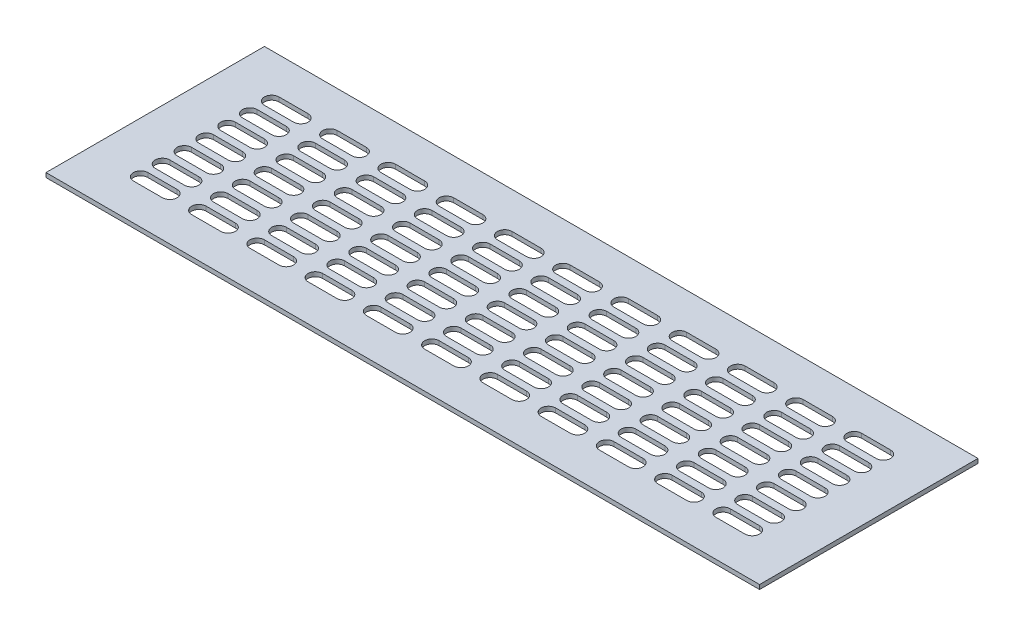
from build123d import *

# Parameters (mm, degrees)
SKETCH1_W           = 490
SKETCH1_H           = 150
BOSS_EXTRUDE1_DEPTH = 1.5
CUT_EXTRUDE1_DEPTH  = 4


with BuildPart() as part:
    # Sketch1 → Boss-Extrude1 (new body, symmetric)
    with BuildSketch(Plane(origin=(0, 0, 0), x_dir=(1, 0, 0), z_dir=(0, 1, 0))):
        Rectangle(SKETCH1_W, SKETCH1_H)
    extrude(amount=BOSS_EXTRUDE1_DEPTH, both=True)

    # Sketch2 → Cut-Extrude1 (cut, through all)
    with BuildSketch(Plane(origin=(0, 1.5, 0), x_dir=(1, 0, 0), z_dir=(0, 1, 0))):
        with BuildLine():
            Line((-210, 50), (-190, 50))
            ThreePointArc((-190, 50), (-185, 45), (-190, 40))
            Line((-190, 40), (-210, 40))
            ThreePointArc((-210, 40), (-215, 45), (-210, 50))
        make_face()
        with BuildLine():
            Line((-170, 50), (-150, 50))
            ThreePointArc((-150, 50), (-145, 45), (-150, 40))
            Line((-150, 40), (-170, 40))
            ThreePointArc((-170, 40), (-175, 45), (-170, 50))
        make_face()
        with BuildLine():
            Line((-130, 50), (-110, 50))
            ThreePointArc((-110, 50), (-105, 45), (-110, 40))
            Line((-110, 40), (-130, 40))
            ThreePointArc((-130, 40), (-135, 45), (-130, 50))
        make_face()
        with BuildLine():
            Line((-90, 50), (-70, 50))
            ThreePointArc((-70, 50), (-65, 45), (-70, 40))
            Line((-70, 40), (-90, 40))
            ThreePointArc((-90, 40), (-95, 45), (-90, 50))
        make_face()
        with BuildLine():
            Line((-50, 50), (-30, 50))
            ThreePointArc((-30, 50), (-25, 45), (-30, 40))
            Line((-30, 40), (-50, 40))
            ThreePointArc((-50, 40), (-55, 45), (-50, 50))
        make_face()
        with BuildLine():
            Line((-10, 50), (10, 50))
            ThreePointArc((10, 50), (15, 45), (10, 40))
            Line((10, 40), (-10, 40))
            ThreePointArc((-10, 40), (-15, 45), (-10, 50))
        make_face()
        with BuildLine():
            Line((30, 50), (50, 50))
            ThreePointArc((50, 50), (55, 45), (50, 40))
            Line((50, 40), (30, 40))
            ThreePointArc((30, 40), (25, 45), (30, 50))
        make_face()
        with BuildLine():
            Line((70, 50), (90, 50))
            ThreePointArc((90, 50), (95, 45), (90, 40))
            Line((90, 40), (70, 40))
            ThreePointArc((70, 40), (65, 45), (70, 50))
        make_face()
        with BuildLine():
            Line((110, 50), (130, 50))
            ThreePointArc((130, 50), (135, 45), (130, 40))
            Line((130, 40), (110, 40))
            ThreePointArc((110, 40), (105, 45), (110, 50))
        make_face()
        with BuildLine():
            Line((150, 50), (170, 50))
            ThreePointArc((170, 50), (175, 45), (170, 40))
            Line((170, 40), (150, 40))
            ThreePointArc((150, 40), (145, 45), (150, 50))
        make_face()
        with BuildLine():
            Line((190, 50), (210, 50))
            ThreePointArc((210, 50), (215, 45), (210, 40))
            Line((210, 40), (190, 40))
            ThreePointArc((190, 40), (185, 45), (190, 50))
        make_face()
        with BuildLine():
            Line((-170, 35), (-150, 35))
            ThreePointArc((-150, 35), (-145, 30), (-150, 25))
            Line((-150, 25), (-170, 25))
            ThreePointArc((-170, 25), (-175, 30), (-170, 35))
        make_face()
        with BuildLine():
            Line((-130, 35), (-110, 35))
            ThreePointArc((-110, 35), (-105, 30), (-110, 25))
            Line((-110, 25), (-130, 25))
            ThreePointArc((-130, 25), (-135, 30), (-130, 35))
        make_face()
        with BuildLine():
            Line((-90, 35), (-70, 35))
            ThreePointArc((-70, 35), (-65, 30), (-70, 25))
            Line((-70, 25), (-90, 25))
            ThreePointArc((-90, 25), (-95, 30), (-90, 35))
        make_face()
        with BuildLine():
            Line((-50, 35), (-30, 35))
            ThreePointArc((-30, 35), (-25, 30), (-30, 25))
            Line((-30, 25), (-50, 25))
            ThreePointArc((-50, 25), (-55, 30), (-50, 35))
        make_face()
        with BuildLine():
            Line((-10, 35), (10, 35))
            ThreePointArc((10, 35), (15, 30), (10, 25))
            Line((10, 25), (-10, 25))
            ThreePointArc((-10, 25), (-15, 30), (-10, 35))
        make_face()
        with BuildLine():
            Line((30, 35), (50, 35))
            ThreePointArc((50, 35), (55, 30), (50, 25))
            Line((50, 25), (30, 25))
            ThreePointArc((30, 25), (25, 30), (30, 35))
        make_face()
        with BuildLine():
            Line((70, 35), (90, 35))
            ThreePointArc((90, 35), (95, 30), (90, 25))
            Line((90, 25), (70, 25))
            ThreePointArc((70, 25), (65, 30), (70, 35))
        make_face()
        with BuildLine():
            Line((110, 35), (130, 35))
            ThreePointArc((130, 35), (135, 30), (130, 25))
            Line((130, 25), (110, 25))
            ThreePointArc((110, 25), (105, 30), (110, 35))
        make_face()
        with BuildLine():
            Line((150, 35), (170, 35))
            ThreePointArc((170, 35), (175, 30), (170, 25))
            Line((170, 25), (150, 25))
            ThreePointArc((150, 25), (145, 30), (150, 35))
        make_face()
        with BuildLine():
            Line((190, 35), (210, 35))
            ThreePointArc((210, 35), (215, 30), (210, 25))
            Line((210, 25), (190, 25))
            ThreePointArc((190, 25), (185, 30), (190, 35))
        make_face()
        with BuildLine():
            Line((-170, 20), (-150, 20))
            ThreePointArc((-150, 20), (-145, 15), (-150, 10))
            Line((-150, 10), (-170, 10))
            ThreePointArc((-170, 10), (-175, 15), (-170, 20))
        make_face()
        with BuildLine():
            Line((-130, 20), (-110, 20))
            ThreePointArc((-110, 20), (-105, 15), (-110, 10))
            Line((-110, 10), (-130, 10))
            ThreePointArc((-130, 10), (-135, 15), (-130, 20))
        make_face()
        with BuildLine():
            Line((-90, 20), (-70, 20))
            ThreePointArc((-70, 20), (-65, 15), (-70, 10))
            Line((-70, 10), (-90, 10))
            ThreePointArc((-90, 10), (-95, 15), (-90, 20))
        make_face()
        with BuildLine():
            Line((-50, 20), (-30, 20))
            ThreePointArc((-30, 20), (-25, 15), (-30, 10))
            Line((-30, 10), (-50, 10))
            ThreePointArc((-50, 10), (-55, 15), (-50, 20))
        make_face()
        with BuildLine():
            Line((-10, 20), (10, 20))
            ThreePointArc((10, 20), (15, 15), (10, 10))
            Line((10, 10), (-10, 10))
            ThreePointArc((-10, 10), (-15, 15), (-10, 20))
        make_face()
        with BuildLine():
            Line((30, 20), (50, 20))
            ThreePointArc((50, 20), (55, 15), (50, 10))
            Line((50, 10), (30, 10))
            ThreePointArc((30, 10), (25, 15), (30, 20))
        make_face()
        with BuildLine():
            Line((70, 20), (90, 20))
            ThreePointArc((90, 20), (95, 15), (90, 10))
            Line((90, 10), (70, 10))
            ThreePointArc((70, 10), (65, 15), (70, 20))
        make_face()
        with BuildLine():
            Line((110, 20), (130, 20))
            ThreePointArc((130, 20), (135, 15), (130, 10))
            Line((130, 10), (110, 10))
            ThreePointArc((110, 10), (105, 15), (110, 20))
        make_face()
        with BuildLine():
            Line((150, 20), (170, 20))
            ThreePointArc((170, 20), (175, 15), (170, 10))
            Line((170, 10), (150, 10))
            ThreePointArc((150, 10), (145, 15), (150, 20))
        make_face()
        with BuildLine():
            Line((190, 20), (210, 20))
            ThreePointArc((210, 20), (215, 15), (210, 10))
            Line((210, 10), (190, 10))
            ThreePointArc((190, 10), (185, 15), (190, 20))
        make_face()
        with BuildLine():
            Line((-170, 5), (-150, 5))
            ThreePointArc((-150, 5), (-145, 0), (-150, -5))
            Line((-150, -5), (-170, -5))
            ThreePointArc((-170, -5), (-175, 0), (-170, 5))
        make_face()
        with BuildLine():
            Line((-130, 5), (-110, 5))
            ThreePointArc((-110, 5), (-105, 0), (-110, -5))
            Line((-110, -5), (-130, -5))
            ThreePointArc((-130, -5), (-135, 0), (-130, 5))
        make_face()
        with BuildLine():
            Line((-90, 5), (-70, 5))
            ThreePointArc((-70, 5), (-65, 0), (-70, -5))
            Line((-70, -5), (-90, -5))
            ThreePointArc((-90, -5), (-95, 0), (-90, 5))
        make_face()
        with BuildLine():
            Line((-50, 5), (-30, 5))
            ThreePointArc((-30, 5), (-25, 0), (-30, -5))
            Line((-30, -5), (-50, -5))
            ThreePointArc((-50, -5), (-55, 0), (-50, 5))
        make_face()
        with BuildLine():
            Line((-10, 5), (10, 5))
            ThreePointArc((10, 5), (15, 0), (10, -5))
            Line((10, -5), (-10, -5))
            ThreePointArc((-10, -5), (-15, 0), (-10, 5))
        make_face()
        with BuildLine():
            Line((30, 5), (50, 5))
            ThreePointArc((50, 5), (55, 0), (50, -5))
            Line((50, -5), (30, -5))
            ThreePointArc((30, -5), (25, 0), (30, 5))
        make_face()
        with BuildLine():
            Line((70, 5), (90, 5))
            ThreePointArc((90, 5), (95, 0), (90, -5))
            Line((90, -5), (70, -5))
            ThreePointArc((70, -5), (65, 0), (70, 5))
        make_face()
        with BuildLine():
            Line((110, 5), (130, 5))
            ThreePointArc((130, 5), (135, 0), (130, -5))
            Line((130, -5), (110, -5))
            ThreePointArc((110, -5), (105, 0), (110, 5))
        make_face()
        with BuildLine():
            Line((150, 5), (170, 5))
            ThreePointArc((170, 5), (175, 0), (170, -5))
            Line((170, -5), (150, -5))
            ThreePointArc((150, -5), (145, 0), (150, 5))
        make_face()
        with BuildLine():
            Line((190, 5), (210, 5))
            ThreePointArc((210, 5), (215, 0), (210, -5))
            Line((210, -5), (190, -5))
            ThreePointArc((190, -5), (185, 0), (190, 5))
        make_face()
        with BuildLine():
            Line((-170, -10), (-150, -10))
            ThreePointArc((-150, -10), (-145, -15), (-150, -20))
            Line((-150, -20), (-170, -20))
            ThreePointArc((-170, -20), (-175, -15), (-170, -10))
        make_face()
        with BuildLine():
            Line((-130, -10), (-110, -10))
            ThreePointArc((-110, -10), (-105, -15), (-110, -20))
            Line((-110, -20), (-130, -20))
            ThreePointArc((-130, -20), (-135, -15), (-130, -10))
        make_face()
        with BuildLine():
            Line((-90, -10), (-70, -10))
            ThreePointArc((-70, -10), (-65, -15), (-70, -20))
            Line((-70, -20), (-90, -20))
            ThreePointArc((-90, -20), (-95, -15), (-90, -10))
        make_face()
        with BuildLine():
            Line((-50, -10), (-30, -10))
            ThreePointArc((-30, -10), (-25, -15), (-30, -20))
            Line((-30, -20), (-50, -20))
            ThreePointArc((-50, -20), (-55, -15), (-50, -10))
        make_face()
        with BuildLine():
            Line((-10, -10), (10, -10))
            ThreePointArc((10, -10), (15, -15), (10, -20))
            Line((10, -20), (-10, -20))
            ThreePointArc((-10, -20), (-15, -15), (-10, -10))
        make_face()
        with BuildLine():
            Line((30, -10), (50, -10))
            ThreePointArc((50, -10), (55, -15), (50, -20))
            Line((50, -20), (30, -20))
            ThreePointArc((30, -20), (25, -15), (30, -10))
        make_face()
        with BuildLine():
            Line((70, -10), (90, -10))
            ThreePointArc((90, -10), (95, -15), (90, -20))
            Line((90, -20), (70, -20))
            ThreePointArc((70, -20), (65, -15), (70, -10))
        make_face()
        with BuildLine():
            Line((110, -10), (130, -10))
            ThreePointArc((130, -10), (135, -15), (130, -20))
            Line((130, -20), (110, -20))
            ThreePointArc((110, -20), (105, -15), (110, -10))
        make_face()
        with BuildLine():
            Line((150, -10), (170, -10))
            ThreePointArc((170, -10), (175, -15), (170, -20))
            Line((170, -20), (150, -20))
            ThreePointArc((150, -20), (145, -15), (150, -10))
        make_face()
        with BuildLine():
            Line((190, -10), (210, -10))
            ThreePointArc((210, -10), (215, -15), (210, -20))
            Line((210, -20), (190, -20))
            ThreePointArc((190, -20), (185, -15), (190, -10))
        make_face()
        with BuildLine():
            Line((-170, -25), (-150, -25))
            ThreePointArc((-150, -25), (-145, -30), (-150, -35))
            Line((-150, -35), (-170, -35))
            ThreePointArc((-170, -35), (-175, -30), (-170, -25))
        make_face()
        with BuildLine():
            Line((-130, -25), (-110, -25))
            ThreePointArc((-110, -25), (-105, -30), (-110, -35))
            Line((-110, -35), (-130, -35))
            ThreePointArc((-130, -35), (-135, -30), (-130, -25))
        make_face()
        with BuildLine():
            Line((-90, -25), (-70, -25))
            ThreePointArc((-70, -25), (-65, -30), (-70, -35))
            Line((-70, -35), (-90, -35))
            ThreePointArc((-90, -35), (-95, -30), (-90, -25))
        make_face()
        with BuildLine():
            Line((-50, -25), (-30, -25))
            ThreePointArc((-30, -25), (-25, -30), (-30, -35))
            Line((-30, -35), (-50, -35))
            ThreePointArc((-50, -35), (-55, -30), (-50, -25))
        make_face()
        with BuildLine():
            Line((-10, -25), (10, -25))
            ThreePointArc((10, -25), (15, -30), (10, -35))
            Line((10, -35), (-10, -35))
            ThreePointArc((-10, -35), (-15, -30), (-10, -25))
        make_face()
        with BuildLine():
            Line((30, -25), (50, -25))
            ThreePointArc((50, -25), (55, -30), (50, -35))
            Line((50, -35), (30, -35))
            ThreePointArc((30, -35), (25, -30), (30, -25))
        make_face()
        with BuildLine():
            Line((70, -25), (90, -25))
            ThreePointArc((90, -25), (95, -30), (90, -35))
            Line((90, -35), (70, -35))
            ThreePointArc((70, -35), (65, -30), (70, -25))
        make_face()
        with BuildLine():
            Line((110, -25), (130, -25))
            ThreePointArc((130, -25), (135, -30), (130, -35))
            Line((130, -35), (110, -35))
            ThreePointArc((110, -35), (105, -30), (110, -25))
        make_face()
        with BuildLine():
            Line((150, -25), (170, -25))
            ThreePointArc((170, -25), (175, -30), (170, -35))
            Line((170, -35), (150, -35))
            ThreePointArc((150, -35), (145, -30), (150, -25))
        make_face()
        with BuildLine():
            Line((190, -25), (210, -25))
            ThreePointArc((210, -25), (215, -30), (210, -35))
            Line((210, -35), (190, -35))
            ThreePointArc((190, -35), (185, -30), (190, -25))
        make_face()
        with BuildLine():
            Line((-170, -40), (-150, -40))
            ThreePointArc((-150, -40), (-145, -45), (-150, -50))
            Line((-150, -50), (-170, -50))
            ThreePointArc((-170, -50), (-175, -45), (-170, -40))
        make_face()
        with BuildLine():
            Line((-130, -40), (-110, -40))
            ThreePointArc((-110, -40), (-105, -45), (-110, -50))
            Line((-110, -50), (-130, -50))
            ThreePointArc((-130, -50), (-135, -45), (-130, -40))
        make_face()
        with BuildLine():
            Line((-90, -40), (-70, -40))
            ThreePointArc((-70, -40), (-65, -45), (-70, -50))
            Line((-70, -50), (-90, -50))
            ThreePointArc((-90, -50), (-95, -45), (-90, -40))
        make_face()
        with BuildLine():
            Line((-50, -40), (-30, -40))
            ThreePointArc((-30, -40), (-25, -45), (-30, -50))
            Line((-30, -50), (-50, -50))
            ThreePointArc((-50, -50), (-55, -45), (-50, -40))
        make_face()
        with BuildLine():
            Line((-10, -40), (10, -40))
            ThreePointArc((10, -40), (15, -45), (10, -50))
            Line((10, -50), (-10, -50))
            ThreePointArc((-10, -50), (-15, -45), (-10, -40))
        make_face()
        with BuildLine():
            Line((30, -40), (50, -40))
            ThreePointArc((50, -40), (55, -45), (50, -50))
            Line((50, -50), (30, -50))
            ThreePointArc((30, -50), (25, -45), (30, -40))
        make_face()
        with BuildLine():
            Line((70, -40), (90, -40))
            ThreePointArc((90, -40), (95, -45), (90, -50))
            Line((90, -50), (70, -50))
            ThreePointArc((70, -50), (65, -45), (70, -40))
        make_face()
        with BuildLine():
            Line((110, -40), (130, -40))
            ThreePointArc((130, -40), (135, -45), (130, -50))
            Line((130, -50), (110, -50))
            ThreePointArc((110, -50), (105, -45), (110, -40))
        make_face()
        with BuildLine():
            Line((150, -40), (170, -40))
            ThreePointArc((170, -40), (175, -45), (170, -50))
            Line((170, -50), (150, -50))
            ThreePointArc((150, -50), (145, -45), (150, -40))
        make_face()
        with BuildLine():
            Line((190, -40), (210, -40))
            ThreePointArc((210, -40), (215, -45), (210, -50))
            Line((210, -50), (190, -50))
            ThreePointArc((190, -50), (185, -45), (190, -40))
        make_face()
        with BuildLine():
            Line((-210, 35), (-190, 35))
            ThreePointArc((-190, 35), (-185, 30), (-190, 25))
            Line((-190, 25), (-210, 25))
            ThreePointArc((-210, 25), (-215, 30), (-210, 35))
        make_face()
        with BuildLine():
            Line((-210, 20), (-190, 20))
            ThreePointArc((-190, 20), (-185, 15), (-190, 10))
            Line((-190, 10), (-210, 10))
            ThreePointArc((-210, 10), (-215, 15), (-210, 20))
        make_face()
        with BuildLine():
            Line((-210, 5), (-190, 5))
            ThreePointArc((-190, 5), (-185, 0), (-190, -5))
            Line((-190, -5), (-210, -5))
            ThreePointArc((-210, -5), (-215, 0), (-210, 5))
        make_face()
        with BuildLine():
            Line((-210, -10), (-190, -10))
            ThreePointArc((-190, -10), (-185, -15), (-190, -20))
            Line((-190, -20), (-210, -20))
            ThreePointArc((-210, -20), (-215, -15), (-210, -10))
        make_face()
        with BuildLine():
            Line((-210, -25), (-190, -25))
            ThreePointArc((-190, -25), (-185, -30), (-190, -35))
            Line((-190, -35), (-210, -35))
            ThreePointArc((-210, -35), (-215, -30), (-210, -25))
        make_face()
        with BuildLine():
            Line((-210, -40), (-190, -40))
            ThreePointArc((-190, -40), (-185, -45), (-190, -50))
            Line((-190, -50), (-210, -50))
            ThreePointArc((-210, -50), (-215, -45), (-210, -40))
        make_face()
    extrude(amount=-CUT_EXTRUDE1_DEPTH, mode=Mode.SUBTRACT)


solid = part.part
